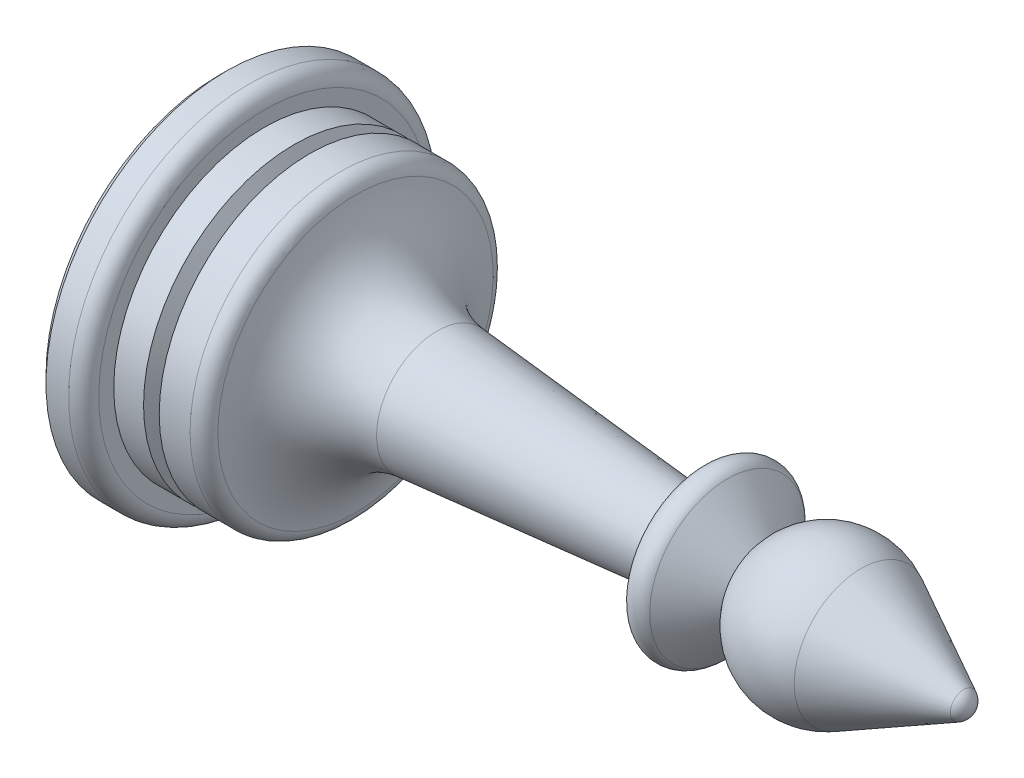
from build123d import *

# Parameters (mm, degrees)
SKETCH3_R          = 6
CUT_EXTRUDE1_DEPTH = 5


with BuildPart() as part:
    # Sketch1 → Revolve1 (revolve)
    with BuildSketch(Plane.XY, mode=Mode.PRIVATE) as revolve1_sk:
        with BuildLine():
            Line((0, 0), (0, 11.5))
            Line((0, 11.5), (0.5, 12))
            Line((0.5, 12), (2, 12))
            ThreePointArc((2, 12), (2.707106781, 11.707106781), (3, 11))
            Line((3, 11), (3, 10))
            Line((3, 10), (8.07179677, 10))
            ThreePointArc((8.07179677, 10), (8.72645044, 9.755928946), (9.061540088, 9.142857143))
            ThreePointArc((9.061540088, 9.142857143), (10.879240455, 5.638883082), (14.480527899, 4.022529905))
            Line((14.480527899, 4.022529905), (32, 2.5))
            Line((32, 2.5), (32, 4.519536951))
            ThreePointArc((32, 4.519536951), (32.657979857, 5.459229572), (33.766044443, 5.162324561))
            Line((33.766044443, 5.162324561), (36, 2.5))
            ThreePointArc((36, 2.5), (38.9299516, 4.799948833), (42.63696589, 4.436044908))
            Line((42.63696589, 4.436044908), (49.461367774, 0.887208982))
            ThreePointArc((49.461367774, 0.887208982), (49.854800496, 0.518956754), (50, 0))
            Line((50, 0), (0, 0))
        make_face()
    revolve(revolve1_sk.sketch.rotate(Axis((0, 0, 0), (1, 0, 0)), 180), axis=Axis((0, 0, 0), (1, 0, 0)))  # turned: the seam where the file's is

    # Sketch2 → Cut-Revolve1 (revolve, cut)
    with BuildSketch(Plane.XY, mode=Mode.PRIVATE) as cut_revolve1_sk:
        Polygon((4.979432949, 10), (5.5, 9), (6.020567051, 10), align=None)
    revolve(cut_revolve1_sk.sketch.rotate(Axis((0, 0, 0), (1, 0, 0)), 180), axis=Axis((0, 0, 0), (1, 0, 0)), mode=Mode.SUBTRACT)  # turned: the seam where the file's is

    # Sketch3 → Cut-Extrude1 (cut)
    with BuildSketch(Plane.ZY):
        with Locations(Location((0, 0, 0), (0, 0, 270))):  # turned: the seam where the file's is
            Circle(SKETCH3_R)
    extrude(amount=-CUT_EXTRUDE1_DEPTH, mode=Mode.SUBTRACT)


solid = part.part
